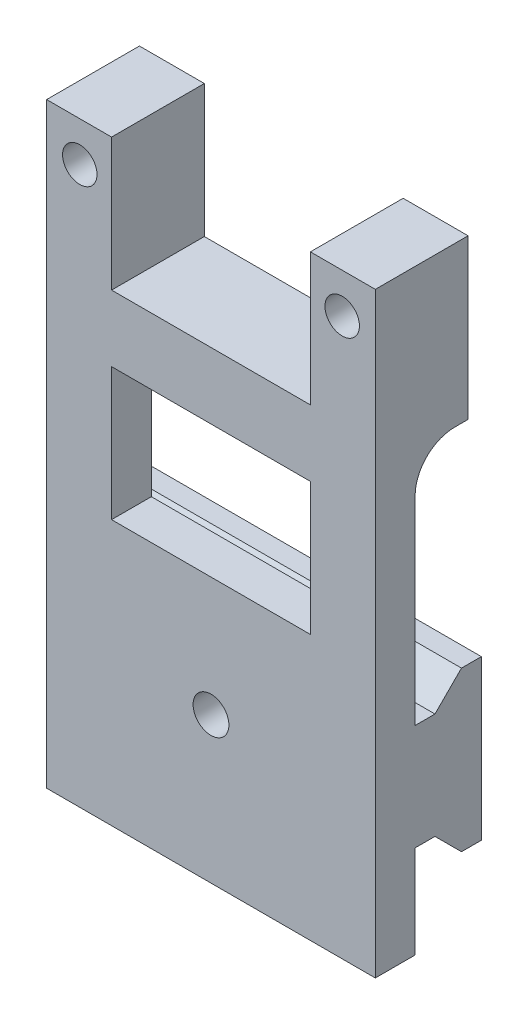
from build123d import *

# Parameters (mm, degrees)
SKETCH1_R                        = 1.3
MAIN_DEPTH                       = 7
SKETCH3_W                        = 4
SKETCH3_H                        = 33
CUT_EXTRUDE1_DEPTH               = 25.8
FIXSUPPORT_DEPTH                 = 12.4
FILLET1_R                        = 3
SKETCH4_W                        = 15
SKETCH4_H                        = 10
CUTFORSCREWRAILACCESS_DEPTH      = 9
SKETCH5_R                        = 1.35
HOLETOBLOCKSYSTEMWITHSCREW_DEPTH = 9


with BuildPart() as part:
    # Sketch1 → Main (new body)
    with BuildSketch(Plane.XY):
        Polygon((-7.5, 10), (-7.5, 0), (7.5, 0), (7.5, 10), (12.4, 10), (12.4, -35), (-12.4, -35), (-12.4, 10), align=None)
        with Locations((-9.9, 7)):
            Circle(SKETCH1_R, mode=Mode.SUBTRACT)
        with Locations((9.9, 7)):
            Circle(SKETCH1_R, mode=Mode.SUBTRACT)
    extrude(amount=MAIN_DEPTH)

    # Sketch3 → Cut-Extrude1 (cut, through all)
    with BuildSketch(Plane.ZY.offset(12.4)):
        with Locations((2, -18.5)):
            Rectangle(SKETCH3_W, SKETCH3_H)
    extrude(amount=-CUT_EXTRUDE1_DEPTH, mode=Mode.SUBTRACT)

    # Sketch2 → FixSupport (add, symmetric)
    with BuildSketch(Plane.ZY):
        Polygon((0.5, -18), (-1, -18), (-1, -30), (0.5, -30), (2.5, -28), (4, -28), (4, -20), (2.5, -20), align=None)
    extrude(amount=FIXSUPPORT_DEPTH, both=True)

    # Fillet1
    fillet1_edges = [part.edges().sort_by_distance(p)[0] for p in [
        (0, -2, 4),
    ]]
    fillet(fillet1_edges, radius=FILLET1_R)

    # Sketch4 → CutForScrewRailAccess (cut, through all)
    with BuildSketch(Plane.XY.offset(7)):
        with Locations((0, -10)):
            Rectangle(SKETCH4_W, SKETCH4_H)
    extrude(amount=-CUTFORSCREWRAILACCESS_DEPTH, mode=Mode.SUBTRACT)

    # Sketch5 → HoleToBlockSystemWithScrew (cut, through all)
    with BuildSketch(Plane.XY.offset(7)):
        with Locations((0, -24)):
            Circle(SKETCH5_R)
    extrude(amount=-HOLETOBLOCKSYSTEMWITHSCREW_DEPTH, mode=Mode.SUBTRACT)


solid = part.part
